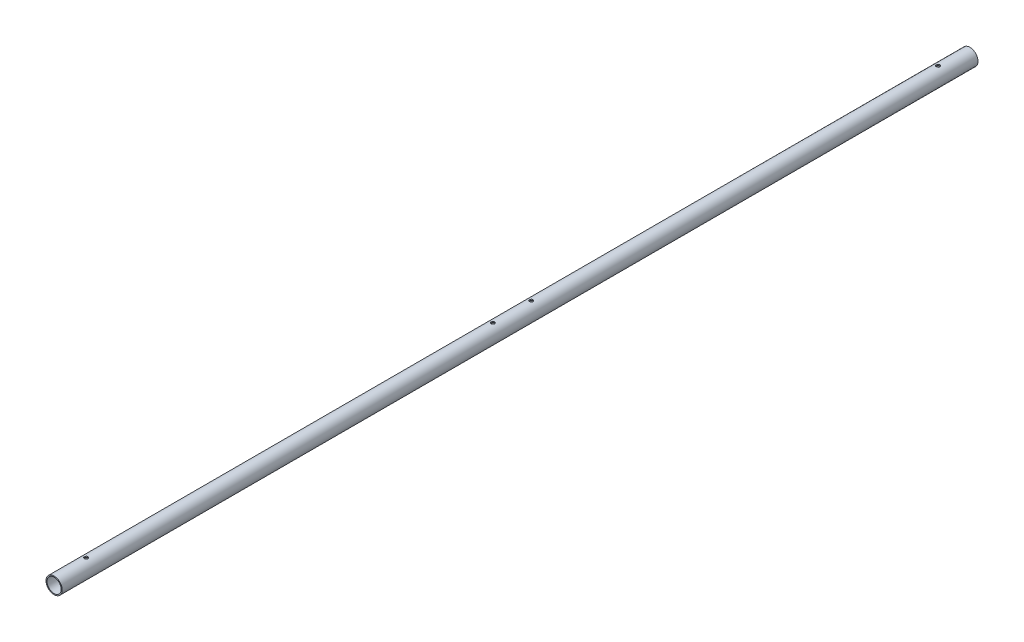
from build123d import *

# Parameters (mm, degrees)
SKETCH1_R                                  = 12.7
SKETCH1_R_2                                = 11.1125
BOSS_EXTRUDE1_DEPTH                        = 716.7546056
M5_CLEARANCE_HOLE1_D                       = 5.5
SKETCH7_W                                  = 2.75
SKETCH7_H                                  = 12.7
MIRROR1_AT_THE_SECOND_PLANE_COPY_1_SKETC_W = 2.75
MIRROR1_AT_THE_SECOND_PLANE_COPY_1_SKETC_H = 12.7


with BuildPart() as part:
    # Sketch1 → Boss-Extrude1 (new, symmetric)
    with BuildSketch(Plane.XY):
        Circle(SKETCH1_R)
        Circle(SKETCH1_R_2, mode=Mode.SUBTRACT)
    extrude(amount=BOSS_EXTRUDE1_DEPTH, both=True)

    # M5 Clearance Hole1 (through all)
    with Locations(Plane(origin=(0, 12.7, 0), x_dir=(1, 0, 0), z_dir=(0, 1, 0))):
        with Locations((0, 30), (0, -30)):
            Hole(M5_CLEARANCE_HOLE1_D / 2)

    # Sketch7 → M5 Clearance Hole2 (revolve, cut)
    with BuildSketch(Plane(origin=(0, 0, 666.7546056), x_dir=(0, 0, -1), z_dir=(1, 0, 0))):
        with Locations((1.375, 6.35)):
            Rectangle(SKETCH7_W, SKETCH7_H)
    m5_clearance_hole2 = revolve(axis=Axis((0, -6.35, 666.7546056), (0, 1, 0)), mode=Mode.SUBTRACT)

    # Mirror1: M5 Clearance Hole2 across plane
    add(m5_clearance_hole2.mirror(Plane.ZX), mode=Mode.SUBTRACT)

    # Mirror1 at the second plane: M5 Clearance Hole2 across plane
    add(m5_clearance_hole2.mirror(Plane.XY), mode=Mode.SUBTRACT)

    # Mirror1 at the second plane copy 1 sketc → Mirror1 at the second plane copy 1 (revolve, cut)
    with BuildSketch(Plane(origin=(0, 0, -666.7546056), x_dir=(0, 0, 1), z_dir=(1, 0, 0))):
        with Locations((1.375, 6.35)):
            Rectangle(MIRROR1_AT_THE_SECOND_PLANE_COPY_1_SKETC_W, MIRROR1_AT_THE_SECOND_PLANE_COPY_1_SKETC_H)
    revolve(axis=Axis((0, 6.35, -666.7546056), (0, -1, 0)), mode=Mode.SUBTRACT)


solid = part.part
